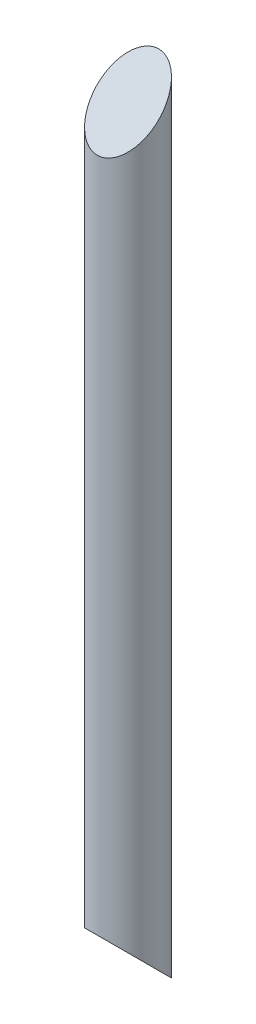
from build123d import *

# Parameters (mm, degrees)
SKETCH1_R           = 31.75
BOSS_EXTRUDE1_DEPTH = 698.5
SKETCH2_R           = 31.75
BOSS_EXTRUDE2_DEPTH = 63.5
SKETCH3_R           = 31.75
BOSS_EXTRUDE3_DEPTH = 63.5
CUT_EXTRUDE1_DEPTH  = 63.5


with BuildPart() as part:
    # Sketch1 → Boss-Extrude1 (new body)
    with BuildSketch(Plane(origin=(0, 0, 0), x_dir=(1, 0, 0), z_dir=(0, 1, 0))):
        Circle(SKETCH1_R)
    extrude(amount=BOSS_EXTRUDE1_DEPTH)

    # Sketch2 → Boss-Extrude2 (add)
    with BuildSketch(Plane(origin=(0, 698.5, 0), x_dir=(1, 0, 0), z_dir=(0, 1, 0))):
        Circle(SKETCH2_R)
    extrude(amount=BOSS_EXTRUDE2_DEPTH)

    # Sketch3 → Boss-Extrude3 (add)
    with BuildSketch(Plane.XZ):
        Circle(SKETCH3_R)
    extrude(amount=BOSS_EXTRUDE3_DEPTH)

    # Sketch4 → Cut-Extrude1 (cut)
    with BuildSketch(Plane(origin=(31.75, 0, 0), x_dir=(0, 0, -1), z_dir=(1, 0, 0))):
        Polygon((-31.75, 762), (-31.75, 698.5), (31.75, 762), align=None)
        Polygon((-31.75, 0), (31.75, -63.5), (-31.75, -63.5), align=None)
    extrude(amount=-CUT_EXTRUDE1_DEPTH, mode=Mode.SUBTRACT)


solid = part.part
